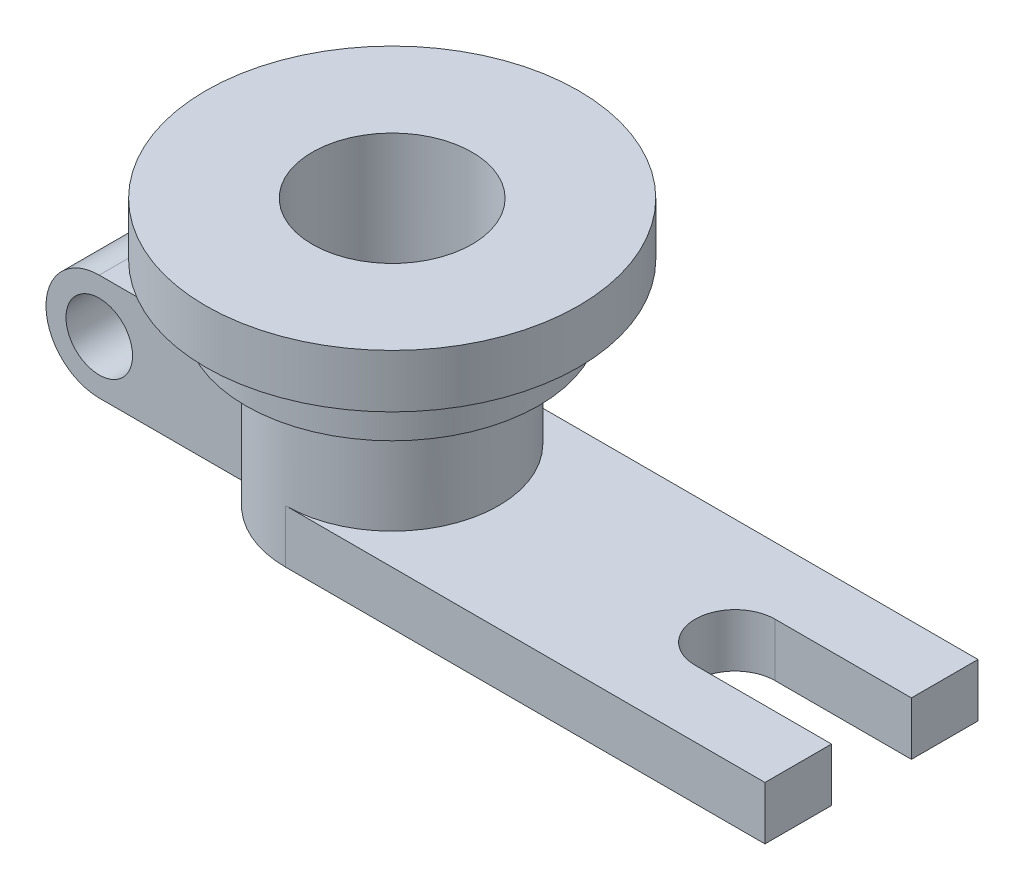
from build123d import *

# Parameters (mm, degrees)
SKETCH1_R           = 55
BOSS_EXTRUDE1_DEPTH = 20
SKETCH2_R           = 70
BOSS_EXTRUDE2_DEPTH = 20
SKETCH3_R           = 40
BOSS_EXTRUDE3_DEPTH = 60
CUT_EXTRUDE1_REACH  = 102
SKETCH4_R           = 30
BOSS_EXTRUDE4_REACH = 252
SKETCH6_W           = 80
SKETCH6_H           = 20
CUT_EXTRUDE2_DEPTH  = 60
BOSS_EXTRUDE5_REACH = 292
SKETCH10_W          = 40
SKETCH10_H          = 40
CUT_EXTRUDE3_DEPTH  = 60
SKETCH12_R          = 12.5
CUT_EXTRUDE4_DEPTH  = 60


with BuildPart() as part:
    # Sketch1 → Boss-Extrude1 (new body)
    with BuildSketch(Plane(origin=(0, 0, 0), x_dir=(1, 0, 0), z_dir=(0, 1, 0))):
        Circle(SKETCH1_R)
    extrude(amount=BOSS_EXTRUDE1_DEPTH)

    # Sketch2 → Boss-Extrude2 (add)
    with BuildSketch(Plane(origin=(0, 20, 0), x_dir=(1, 0, 0), z_dir=(0, 1, 0))):
        Circle(SKETCH2_R)
    extrude(amount=BOSS_EXTRUDE2_DEPTH)

    # Sketch3 → Boss-Extrude3 (add)
    with BuildSketch(Plane.XZ):
        Circle(SKETCH3_R)
    extrude(amount=BOSS_EXTRUDE3_DEPTH)

    # Sketch4 → Cut-Extrude1 (cut, up to next)
    with BuildSketch(Plane(origin=(0, 40, 0), x_dir=(1, 0, 0), z_dir=(0, 1, 0)), mode=Mode.PRIVATE) as cut_extrude1_sk1:
        Circle(SKETCH4_R)
    cut_extrude1_tool1 = extrude(cut_extrude1_sk1.sketch, amount=-CUT_EXTRUDE1_REACH, mode=Mode.PRIVATE) & part.part
    add(cut_extrude1_tool1.solids().sort_by_distance((0, 40, 0))[0], mode=Mode.SUBTRACT)

    # Sketch6 → Boss-Extrude4 (add, up to next)
    with BuildSketch(Plane(origin=(180, 0, 0), x_dir=(0, 0, -1), z_dir=(1, 0, 0)), mode=Mode.PRIVATE) as boss_extrude4_sk1:
        with Locations((0, -50)):
            Rectangle(SKETCH6_W, SKETCH6_H)
    boss_extrude4_tool1 = extrude(boss_extrude4_sk1.sketch, amount=-BOSS_EXTRUDE4_REACH, mode=Mode.PRIVATE) - part.part
    add(boss_extrude4_tool1.solids().sort_by_distance((180, -50, 0))[0])

    # Sketch8 → Cut-Extrude2 (cut)
    with BuildSketch(Plane(origin=(0, -40, 0), x_dir=(1, 0, 0), z_dir=(0, 1, 0))):
        with BuildLine():
            Line((180, 15), (180, -15))
            Line((180, -15), (128.7735226, -15))
            ThreePointArc((128.7735226, -15), (113.7735226, 0), (128.7735226, 15))
            Line((128.7735226, 15), (180, 15))
        make_face()
    extrude(amount=-CUT_EXTRUDE2_DEPTH, mode=Mode.SUBTRACT)

    # Sketch10 → Boss-Extrude5 (add, up to next)
    with BuildSketch(Plane(origin=(-110, 0, 0), x_dir=(0, 0, -1), z_dir=(1, 0, 0)), mode=Mode.PRIVATE) as boss_extrude5_sk1:
        with Locations((0, -40)):
            Rectangle(SKETCH10_W, SKETCH10_H)
    boss_extrude5_tool1 = extrude(boss_extrude5_sk1.sketch, amount=BOSS_EXTRUDE5_REACH, mode=Mode.PRIVATE) - part.part
    add(boss_extrude5_tool1.solids().sort_by_distance((-110, -40, 0))[0])

    # Sketch11 → Cut-Extrude3 (cut)
    with BuildSketch(Plane.XY.offset(20)):
        with BuildLine():
            ThreePointArc((-110, -40), (-104.142135624, -25.857864376), (-90, -20))
            Line((-90, -20), (-110, -20))
            Line((-110, -20), (-110, -40))
        make_face()
        with BuildLine():
            ThreePointArc((-90, -60), (-104.142135624, -54.142135624), (-110, -40))
            Line((-110, -40), (-110, -60))
            Line((-110, -60), (-90, -60))
        make_face()
    extrude(amount=-CUT_EXTRUDE3_DEPTH, mode=Mode.SUBTRACT)

    # Sketch12 → Cut-Extrude4 (cut)
    with BuildSketch(Plane.XY.offset(20)):
        with Locations((-90, -40)):
            Circle(SKETCH12_R)
    extrude(amount=-CUT_EXTRUDE4_DEPTH, mode=Mode.SUBTRACT)


solid = part.part
